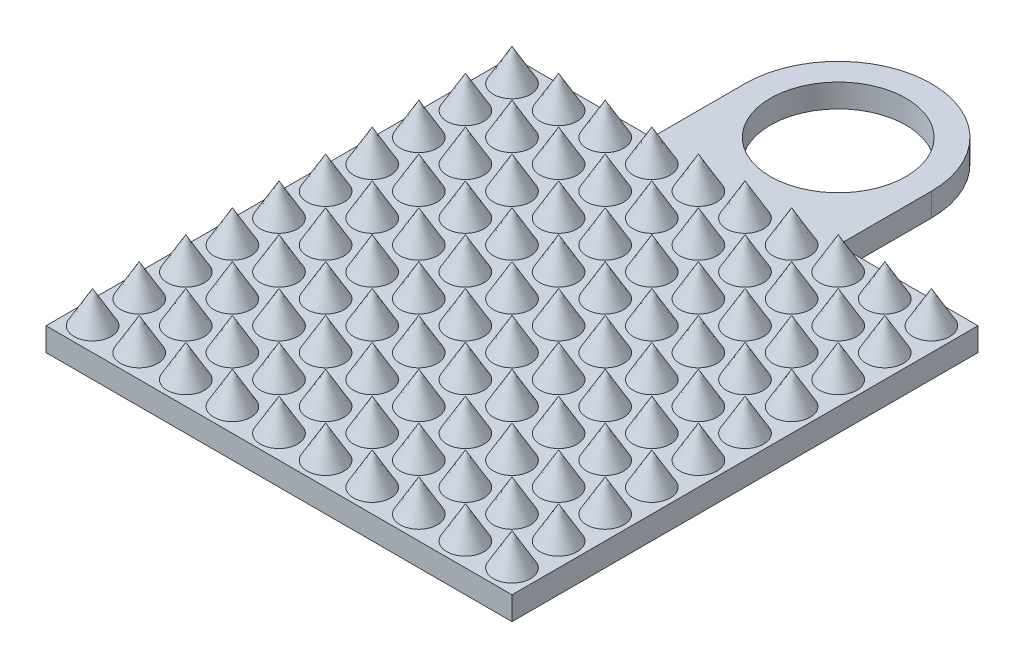
from build123d import *

# Parameters (mm, degrees)
SKETCH1_W               = 10
SKETCH1_H               = 10
PLATE_DEPTH             = 0.5
BOSS_EXTRUDE3_DEPTH     = 0.5
CUT_EXTRUDE1_DEPTH      = 0.5
CUT_EXTRUDE1_DEPTH_BACK = 1.5
SKETCH5_R               = 1.455938962
LPATTERN1_COUNT         = 10
LPATTERN1_PITCH         = 1
LPATTERN1_COUNT_DIR2    = 10
LPATTERN1_PITCH_DIR2    = 1


with BuildPart() as part:
    # Sketch1 → Plate (new body)
    with BuildSketch(Plane(origin=(0, 0, 0), x_dir=(1, 0, 0), z_dir=(0, 1, 0))):
        Rectangle(SKETCH1_W, SKETCH1_H)
    extrude(amount=PLATE_DEPTH)

    # Sketch4 → Boss-Extrude3 (add)
    with BuildSketch(Plane(origin=(0, 0, 0), x_dir=(1, 0, 0), z_dir=(0, 1, 0))):
        with BuildLine():
            Line((-2, 7), (-2, 5))
            Line((-2, 5), (2, 5))
            Line((2, 5), (2, 7))
            ThreePointArc((2, 7), (0, 9), (-2, 7))
        make_face()
    extrude(amount=BOSS_EXTRUDE3_DEPTH)

    # Sketch5 → Cut-Extrude1 (cut, two sides: drawn at the far end of the back side and taken through both)
    with BuildSketch(Plane(origin=(0, 0.5, 0), x_dir=(1, 0, 0), z_dir=(0, 1, 0)).offset(-CUT_EXTRUDE1_DEPTH_BACK)):
        with Locations(Location((0, 7, 0), (0, 0, 270))):
            Circle(SKETCH5_R)
    extrude(amount=CUT_EXTRUDE1_DEPTH + CUT_EXTRUDE1_DEPTH_BACK, mode=Mode.SUBTRACT)

    # Boss-Extrude4 cone 1 section (through the dimple's axis) → Boss-Extrude4 (revolve)
    with BuildSketch(Plane(origin=(-4.5, 0.5, 4.5), x_dir=(0, 0, -1), z_dir=(1, 0, 0))):
        Polygon((0, 0), (0.4, 0), (0, 0.692820323), align=None)
    boss_extrude4 = revolve(axis=Axis((-4.5, 0.5, 4.5), (0, 1, 0)))

    # LPattern1: Boss-Extrude4 10 × 10
    with Locations(*[(i * LPATTERN1_PITCH, 0, -j * LPATTERN1_PITCH_DIR2) for i in range(LPATTERN1_COUNT) for j in range(LPATTERN1_COUNT_DIR2) if (i, j) != (0, 0)]):
        add(boss_extrude4)


solid = part.part
